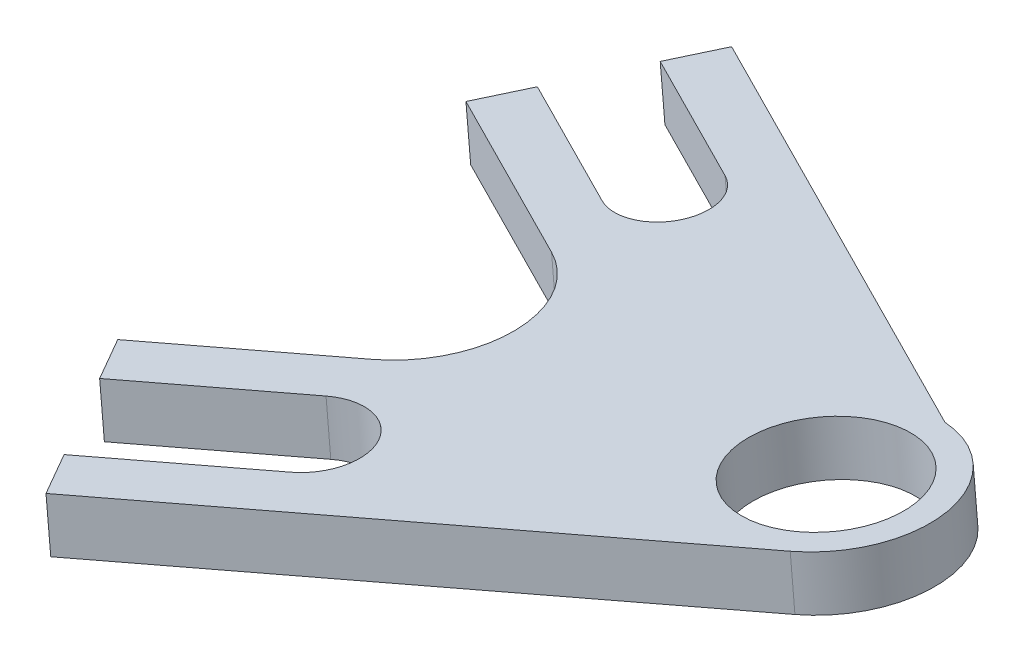
from build123d import *

# Parameters (mm, degrees)
SKETCH1_R           = 12.573
SKETCH1_R_2         = 9.398
BOSS_EXTRUDE1_DEPTH = 3.175
FILLET1_R           = 12.7


with BuildPart() as part:
    # Sketch1 → Boss-Extrude1 (new body, symmetric)
    with BuildSketch(Plane(origin=(-54.155377654, 613.87875058, 32.992743825), x_dir=(0, 0, 1), z_dir=(-0.090029847, 0.995939068, 0))):
        with BuildLine():
            Line((1.896014785, 593.288148249), (-29.623565633, 535.82564653))
            Line((-29.623565633, 535.82564653), (-24.056128994, 532.771772062))
            Line((-24.056128994, 532.771772062), (-14.466963164, 550.253523109))
            ThreePointArc((-14.466963164, 550.253523109), (-7.052635612, 552.415186576), (-4.890972145, 545.000859024))
            Line((-4.890972145, 545.000859024), (-14.480137975, 527.519107976))
            Line((-14.480137975, 527.519107976), (-8.912701335, 524.465233508))
            Line((-8.912701335, 524.465233508), (14.368665453, 566.908868904))
            Line((14.368665453, 566.908868904), (3.548423472, 584.90983519))
            ThreePointArc((3.548423472, 584.90983519), (1.989104795, 588.954403604), (1.896014785, 593.288148249))
        make_face()
        with BuildLine():
            ThreePointArc((22.606879083, 581.927735227), (12.380822619, 578.965387193), (3.548423472, 584.90983519))
            Line((3.548423472, 584.90983519), (14.368665453, 566.908868904))
            Line((14.368665453, 566.908868904), (22.606879083, 581.927735227))
        make_face()
        with BuildLine():
            Line((58.865434837, 541.692100135), (25.100547859, 597.864650913))
            ThreePointArc((25.100547859, 597.864650913), (26.43992538, 594.748262171), (26.897485666, 591.387243051))
            ThreePointArc((26.897485666, 591.387243051), (25.774700979, 586.193699148), (22.606879083, 581.927735227))
            Line((22.606879083, 581.927735227), (14.368665453, 566.908868904))
            Line((14.368665453, 566.908868904), (37.31331045, 528.737284412))
            Line((37.31331045, 528.737284412), (42.755766103, 532.008702524))
            Line((42.755766103, 532.008702524), (32.483513232, 549.098013274))
            ThreePointArc((32.483513232, 549.098013274), (34.611130022, 557.637609564), (43.150726312, 555.509992774))
            Line((43.150726312, 555.509992774), (53.422979184, 538.420682023))
            Line((53.422979184, 538.420682023), (58.865434837, 541.692100135))
        make_face()
        with Locations((14.324485666, 591.387243051)):
            Circle(SKETCH1_R)
        with Locations((14.324485666, 591.387243051)):
            Circle(SKETCH1_R_2, mode=Mode.SUBTRACT)
    extrude(amount=BOSS_EXTRUDE1_DEPTH, both=True)

    # Fillet1
    fillet1_edges = [part.edges().sort_by_distance(p)[0] for p in [
        (510.451312753, 664.917469113, 47.361409278),
    ]]
    fillet(fillet1_edges, radius=FILLET1_R)


solid = part.part
